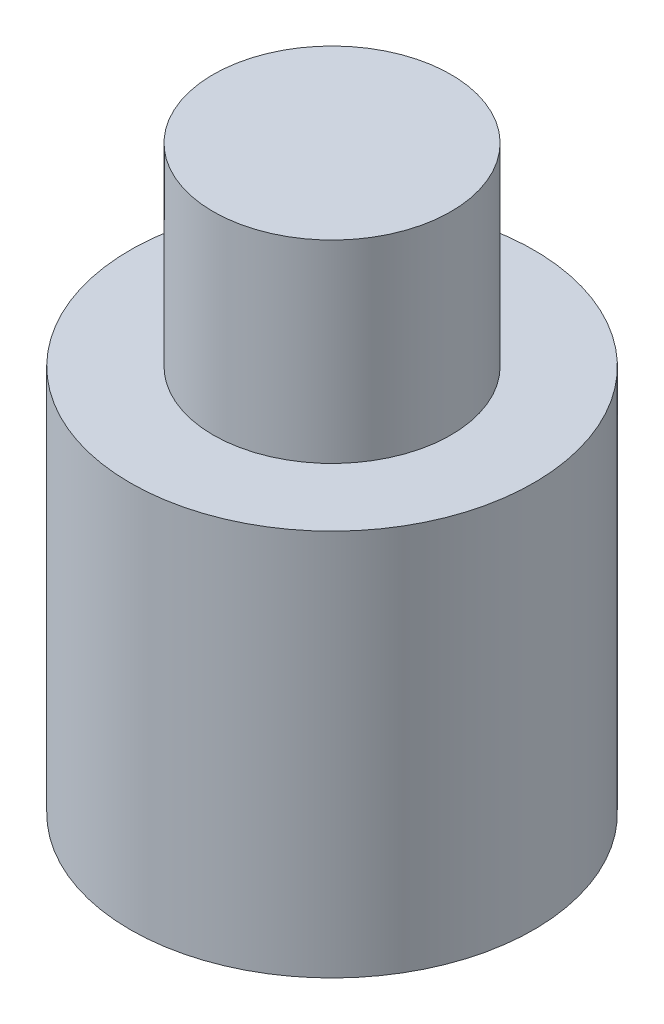
from build123d import *

# Parameters (mm, degrees)
CROQUIS1_R              = 3.65
CROQUIS1_R_2            = 2.65
SALIENTE_EXTRUIR1_DEPTH = 3.5
CROQUIS2_R              = 3.65
SALIENTE_EXTRUIR2_DEPTH = 3.5
CROQUIS3_R              = 2.15
SALIENTE_EXTRUIR3_DEPTH = 3.5


with BuildPart() as part:
    # Croquis1 → Saliente-Extruir1 (new body)
    with BuildSketch(Plane(origin=(0, 0, 0), x_dir=(1, 0, 0), z_dir=(0, 1, 0))):
        Circle(CROQUIS1_R)
        Circle(CROQUIS1_R_2, mode=Mode.SUBTRACT)
    extrude(amount=SALIENTE_EXTRUIR1_DEPTH)

    # Croquis2 → Saliente-Extruir2 (add)
    with BuildSketch(Plane(origin=(0, 3.5, 0), x_dir=(1, 0, 0), z_dir=(0, 1, 0))):
        Circle(CROQUIS2_R)
    extrude(amount=SALIENTE_EXTRUIR2_DEPTH)

    # Croquis3 → Saliente-Extruir3 (add)
    with BuildSketch(Plane(origin=(0, 7, 0), x_dir=(1, 0, 0), z_dir=(0, 1, 0))):
        Circle(CROQUIS3_R)
    extrude(amount=SALIENTE_EXTRUIR3_DEPTH)


solid = part.part
